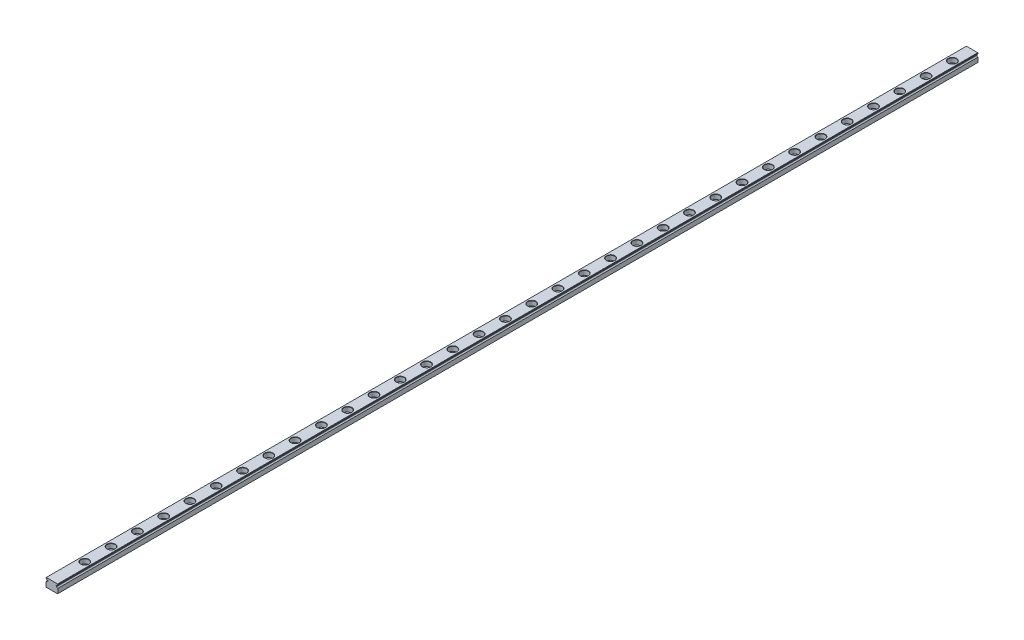
from build123d import *

# Parameters (mm, degrees)
EXTRUDE1_DEPTH             = 700
EXTRUDE2_REACH             = 702.045
SKETCH2_R                  = 1.75
SKETCH_R                   = 3
SKETCH_R_2                 = 1.75
EXTRUDE4_DEPTH             = 3.5
CHAMFER1_SIZE              = 0.2
LPATTERN1_COUNT            = 34
LPATTERN1_PITCH            = 20
CHAMFER1_OF_LPATTERN1_SIZE = 0.2


with BuildPart() as part:
    # Sketch1 → Extrude1 (new body)
    with BuildSketch(Plane.XY):
        with BuildLine():
            Line((-4.3, -3.25), (4.3, -3.25))
            Line((4.3, -3.25), (4.5, -3.05))
            Line((4.5, -3.05), (4.5, 0.455012563))
            ThreePointArc((4.5, 0.455012563), (3.924845827, 0.712323349), (3.617735397, 1.2625))
            Line((3.617735397, 1.2625), (3.15008224, 1.2625))
            Line((3.15008224, 1.2625), (3.15008224, 1.7625))
            Line((3.15008224, 1.7625), (3.65008224, 1.7625))
            ThreePointArc((3.65008224, 1.7625), (3.973877727, 2.229724887), (4.5, 2.444987437))
            Line((4.5, 2.444987437), (4.5, 3.05))
            Line((4.5, 3.05), (4.3, 3.25))
            Line((4.3, 3.25), (-4.3, 3.25))
            Line((-4.3, 3.25), (-4.5, 3.05))
            Line((-4.5, 3.05), (-4.5, 2.444987437))
            ThreePointArc((-4.5, 2.444987437), (-3.973877727, 2.229724887), (-3.65008224, 1.7625))
            Line((-3.65008224, 1.7625), (-3.15008224, 1.7625))
            Line((-3.15008224, 1.7625), (-3.15008224, 1.2625))
            Line((-3.15008224, 1.2625), (-3.617735397, 1.2625))
            ThreePointArc((-3.617735397, 1.2625), (-3.924845827, 0.712323349), (-4.5, 0.455012563))
            Line((-4.5, 0.455012563), (-4.5, -3.05))
            Line((-4.5, -3.05), (-4.3, -3.25))
        make_face()
    extrude(amount=EXTRUDE1_DEPTH)

    # Sketch2 → Extrude2 (cut, up to next)
    with BuildSketch(Plane(origin=(0, 3.25, 0), x_dir=(1, 0, 0), z_dir=(0, 1, 0)), mode=Mode.PRIVATE) as extrude2_sk1:
        with Locations((0, -15)):
            Circle(SKETCH2_R)
    extrude2_tool1 = extrude(extrude2_sk1.sketch, amount=-EXTRUDE2_REACH, mode=Mode.PRIVATE) & part.part
    extrude2 = extrude2_tool1.solids().sort_by_distance((0, 3.25, 15))[0]
    add(extrude2, mode=Mode.SUBTRACT)

    # Sketch → Extrude4 (cut)
    with BuildSketch(Plane(origin=(0, 3.25, 0), x_dir=(1, 0, 0), z_dir=(0, 1, 0))):
        with Locations((0, -15)):
            Circle(SKETCH_R)
        with Locations((0, -15)):
            Circle(SKETCH_R_2, mode=Mode.SUBTRACT)
    extrude4 = extrude(amount=-EXTRUDE4_DEPTH, mode=Mode.SUBTRACT)

    # Chamfer1
    chamfer1_edges = [part.edges().sort_by_distance(p)[0] for p in [
        (-1.75, -3.25, 15),
        (-3, 3.25, 15),
    ]]
    chamfer(chamfer1_edges, length=CHAMFER1_SIZE)

    # LPattern1: Extrude2, Extrude4 ×34
    with Locations(*[(0, 0, i * LPATTERN1_PITCH) for i in range(1, LPATTERN1_COUNT)]):
        add(extrude2, mode=Mode.SUBTRACT)
        add(extrude4, mode=Mode.SUBTRACT)

    # Chamfer1 of LPattern1
    chamfer1_of_lpattern1_edges = [part.edges().sort_by_distance(p)[0] for p in [
        (-1.75, -3.25, 35),
        (-3, 3.25, 35),
        (-1.75, -3.25, 55),
        (-3, 3.25, 55),
        (-1.75, -3.25, 75),
        (-3, 3.25, 75),
        (-1.75, -3.25, 95),
        (-3, 3.25, 95),
        (-1.75, -3.25, 115),
        (-3, 3.25, 115),
        (-1.75, -3.25, 135),
        (-3, 3.25, 135),
        (-1.75, -3.25, 155),
        (-3, 3.25, 155),
        (-1.75, -3.25, 175),
        (-3, 3.25, 175),
        (-1.75, -3.25, 195),
        (-3, 3.25, 195),
        (-1.75, -3.25, 215),
        (-3, 3.25, 215),
        (-1.75, -3.25, 235),
        (-3, 3.25, 235),
        (-1.75, -3.25, 255),
        (-3, 3.25, 255),
        (-1.75, -3.25, 275),
        (-3, 3.25, 275),
        (-1.75, -3.25, 295),
        (-3, 3.25, 295),
        (-1.75, -3.25, 315),
        (-3, 3.25, 315),
        (-1.75, -3.25, 335),
        (-3, 3.25, 335),
        (-1.75, -3.25, 355),
        (-3, 3.25, 355),
        (-1.75, -3.25, 375),
        (-3, 3.25, 375),
        (-1.75, -3.25, 395),
        (-3, 3.25, 395),
        (-1.75, -3.25, 415),
        (-3, 3.25, 415),
        (-1.75, -3.25, 435),
        (-3, 3.25, 435),
        (-1.75, -3.25, 455),
        (-3, 3.25, 455),
        (-1.75, -3.25, 475),
        (-3, 3.25, 475),
        (-1.75, -3.25, 495),
        (-3, 3.25, 495),
        (-1.75, -3.25, 515),
        (-3, 3.25, 515),
        (-1.75, -3.25, 535),
        (-3, 3.25, 535),
        (-1.75, -3.25, 555),
        (-3, 3.25, 555),
        (-1.75, -3.25, 575),
        (-3, 3.25, 575),
        (-1.75, -3.25, 595),
        (-3, 3.25, 595),
        (-1.75, -3.25, 615),
        (-3, 3.25, 615),
        (-1.75, -3.25, 635),
        (-3, 3.25, 635),
        (-1.75, -3.25, 655),
        (-3, 3.25, 655),
        (-1.75, -3.25, 675),
        (-3, 3.25, 675),
    ]]
    chamfer(chamfer1_of_lpattern1_edges, length=CHAMFER1_OF_LPATTERN1_SIZE)


solid = part.part
